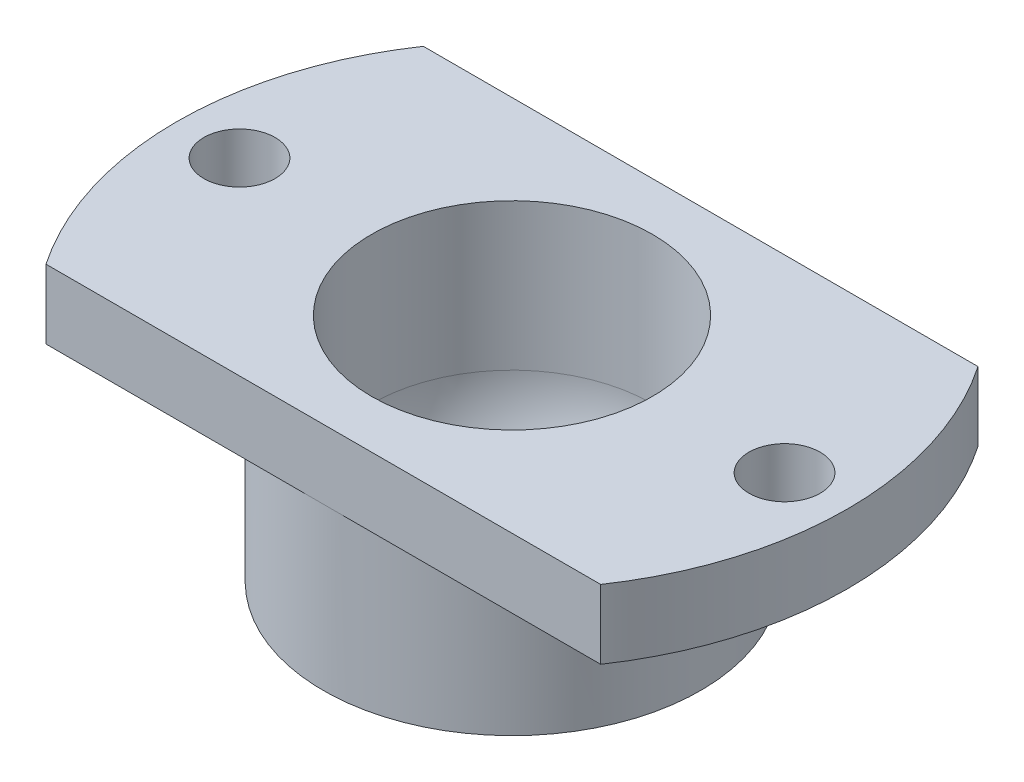
from build123d import *

# Parameters (mm, degrees)
CIRPATTERN2_COUNT  = 2
SKETCH5_W          = 50.426982916
SKETCH5_H          = 37.261009064
SKETCH5_W_2        = 37.991098709
SKETCH5_H_2        = 18
CUT_EXTRUDE1_DEPTH = 4.3


with BuildPart() as part:
    # Sketch1 → Revolve1 (revolve)
    with BuildSketch(Plane(origin=(0, 0, 0), x_dir=(0, 0, -1), z_dir=(1, 0, 0))):
        with BuildLine():
            ThreePointArc((-6.7, 0), (-6.360114404, -2.10688034), (-5.37494186, -4))
            Line((-5.37494186, -4), (-9, -4))
            Line((-9, -4), (-9, 3.7))
            Line((-9, 3.7), (-16, 3.7))
            Line((-16, 3.7), (-16, 7))
            Line((-16, 7), (-6.7, 7))
            Line((-6.7, 7), (-6.7, 0))
        make_face()
    revolve(axis=Axis((0, 0, 0), (0, 1, 0)))

    # Sketch3 → M3 Clearance Hole1 (revolve, cut)
    with BuildSketch(Plane(origin=(-13, 3.7, 0), x_dir=(0, 0, -1), z_dir=(1, 0, 0))):
        Polygon((0, 0), (0, 11.021463052), (1.7, 10), (1.7, 0), align=None)
    m3_clearance_hole1 = revolve(axis=Axis((-13, -2.65, 0), (0, 1, 0)), mode=Mode.SUBTRACT)

    # CirPattern2: M3 Clearance Hole1 ×2 about axis
    cirpattern2_axis = Axis((0, 0, 0), (0, 1, 0))
    for i in range(1, CIRPATTERN2_COUNT):
        add(m3_clearance_hole1.rotate(cirpattern2_axis, i * 360 / CIRPATTERN2_COUNT), mode=Mode.SUBTRACT)

    # Sketch5 → Cut-Extrude1 (cut, through all)
    with BuildSketch(Plane.XZ.offset(-3.7)):
        with Locations((1.488148737, -0.857756759)):
            Rectangle(SKETCH5_W, SKETCH5_H)
        with Locations((1.919239442, 0)):
            Rectangle(SKETCH5_W_2, SKETCH5_H_2, mode=Mode.SUBTRACT)
    extrude(amount=-CUT_EXTRUDE1_DEPTH, mode=Mode.SUBTRACT)


solid = part.part
